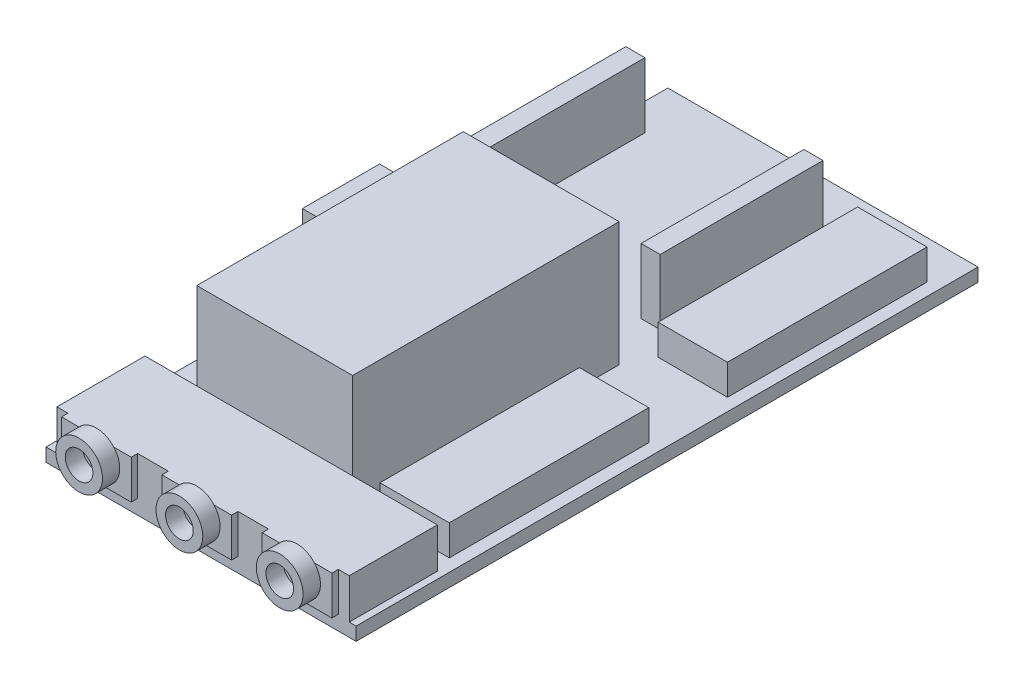
from build123d import *

# Parameters (mm, degrees)
SKETCH1_W           = 39.8
SKETCH1_H           = 79.8
BOSS_EXTRUDE1_DEPTH = 1.7
SKETCH2_W           = 20
SKETCH2_H           = 34.2
BOSS_EXTRUDE2_DEPTH = 15.9
SKETCH3_W           = 2.45
SKETCH3_H           = 20.9
BOSS_EXTRUDE3_DEPTH = 8.35
SKETCH4_W           = 7.63
SKETCH4_H           = 9.9
BOSS_EXTRUDE4_DEPTH = 10.05
SKETCH5_W           = 8.9
SKETCH5_H           = 25.6
BOSS_EXTRUDE5_DEPTH = 3.9
SKETCH6_W           = 37.52
SKETCH6_H           = 11.3
BOSS_EXTRUDE6_DEPTH = 5.16
SKETCH7_W           = 8.95
SKETCH7_H           = 5
BOSS_EXTRUDE7_DEPTH = 0.82
SKETCH8_R           = 3
SKETCH8_R_2         = 1.775
BOSS_EXTRUDE8_DEPTH = 2.22
LPATTERN1_COUNT     = 2
LPATTERN1_PITCH     = 12.875
LPATTERN2_COUNT     = 2
LPATTERN2_PITCH     = 12.875


with BuildPart() as part:
    # Sketch1 → Boss-Extrude1 (new body)
    with BuildSketch(Plane(origin=(0, 0, 0), x_dir=(1, 0, 0), z_dir=(0, 1, 0))):
        Rectangle(SKETCH1_W, SKETCH1_H)
    extrude(amount=BOSS_EXTRUDE1_DEPTH)

    # Sketch2 → Boss-Extrude2 (add)
    with BuildSketch(Plane(origin=(0, 1.7, 0), x_dir=(1, 0, 0), z_dir=(0, 1, 0))):
        with Locations((-2.27, -11.08)):
            Rectangle(SKETCH2_W, SKETCH2_H)
    extrude(amount=BOSS_EXTRUDE2_DEPTH)

    # Sketch3 → Boss-Extrude3 (add)
    with BuildSketch(Plane(origin=(0, 1.7, 0), x_dir=(1, 0, 0), z_dir=(0, 1, 0))):
        with Locations((-17.615, 23)):
            Rectangle(SKETCH3_W, SKETCH3_H)
        with Locations((5.235, 23)):
            Rectangle(SKETCH3_W, SKETCH3_H)
    extrude(amount=BOSS_EXTRUDE3_DEPTH)

    # Sketch4 → Boss-Extrude4 (add)
    with BuildSketch(Plane(origin=(0, 1.7, 0), x_dir=(1, 0, 0), z_dir=(0, 1, 0))):
        with Locations((-16.085, -2.05)):
            Rectangle(SKETCH4_W, SKETCH4_H)
    extrude(amount=BOSS_EXTRUDE4_DEPTH)

    # Sketch5 → Boss-Extrude5 (add)
    with BuildSketch(Plane(origin=(0, 1.7, 0), x_dir=(1, 0, 0), z_dir=(0, 1, 0))):
        with Locations((13.85, -13.55)):
            Rectangle(SKETCH5_W, SKETCH5_H)
        with Locations((13.85, 22.15)):
            Rectangle(SKETCH5_W, SKETCH5_H)
    extrude(amount=BOSS_EXTRUDE5_DEPTH)

    # Sketch6 → Boss-Extrude6 (add)
    with BuildSketch(Plane(origin=(0, 1.7, 0), x_dir=(1, 0, 0), z_dir=(0, 1, 0))):
        with Locations((0.26, -34.25)):
            Rectangle(SKETCH6_W, SKETCH6_H)
    extrude(amount=BOSS_EXTRUDE6_DEPTH)

    # Sketch7 → Boss-Extrude7 (add)
    with BuildSketch(Plane.XY.offset(39.9)):
        with Locations((0.26, 4.36)):
            Rectangle(SKETCH7_W, SKETCH7_H)
    boss_extrude7 = extrude(amount=BOSS_EXTRUDE7_DEPTH)

    # Sketch8 → Boss-Extrude8 (add)
    with BuildSketch(Plane.XY.offset(40.72)):
        with Locations((0.26, 4.86)):
            Circle(SKETCH8_R)
        with Locations((0.26, 4.86)):
            Circle(SKETCH8_R_2, mode=Mode.SUBTRACT)
    boss_extrude8 = extrude(amount=BOSS_EXTRUDE8_DEPTH)

    # LPattern1: Boss-Extrude7, Boss-Extrude8 ×2
    with Locations(*[(-i * LPATTERN1_PITCH, 0, 0) for i in range(1, LPATTERN1_COUNT)]):
        add(boss_extrude7)
        add(boss_extrude8)

    # LPattern2: Boss-Extrude7, Boss-Extrude8 ×2
    with Locations(*[(i * LPATTERN2_PITCH, 0, 0) for i in range(1, LPATTERN2_COUNT)]):
        add(boss_extrude7)
        add(boss_extrude8)


solid = part.part
